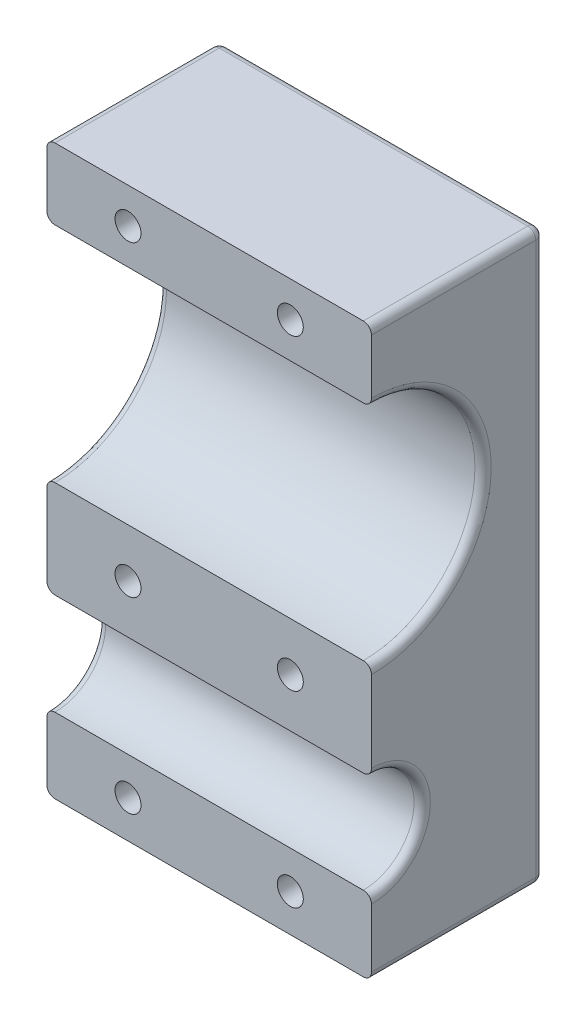
from build123d import *

# Parameters (mm, degrees)
SKETCH1_W           = 53.975
SKETCH1_H           = 88.9
SKETCH1_R           = 7.9375
SKETCH1_R_2         = 17.4625
BOSS_EXTRUDE1_DEPTH = 50.8
SKETCH5_R           = 2.032
CUT_EXTRUDE1_DEPTH  = 116.746060948
SKETCH5_3_R         = 3.5
CUT_EXTRUDE2_DEPTH  = 4.064
CUT_EXTRUDE3_DEPTH  = 2.54
FILLET1_R           = 1.27


with BuildPart() as part:
    # Sketch1 → Boss-Extrude1 (new body)
    with BuildSketch(Plane(origin=(0, 0, 0), x_dir=(0, 0, -1), z_dir=(1, 0, 0))):
        with Locations((26.9875, 44.45)):
            Rectangle(SKETCH1_W, SKETCH1_H)
        with Locations(Location((26.9875, 19.685, 0), (0, 0, 180))):
            Circle(SKETCH1_R, mode=Mode.SUBTRACT)
        with Locations(Location((26.9875, 60.325, 0), (0, 0, 180))):
            Circle(SKETCH1_R_2, mode=Mode.SUBTRACT)
    extrude(amount=BOSS_EXTRUDE1_DEPTH)

    # Sketch5 → Cut-Extrude1 (cut, through all)
    with BuildSketch(Plane.XY):
        with Locations((12.7, 83.34375)):
            Circle(SKETCH5_R)
        with Locations((12.7, 35.2425)):
            Circle(SKETCH5_R)
        with Locations((38.1, 83.34375)):
            Circle(SKETCH5_R)
        with Locations((38.1, 35.2425)):
            Circle(SKETCH5_R)
        with Locations((12.7, 5.87375)):
            Circle(SKETCH5_R)
        with Locations((38.1, 5.87375)):
            Circle(SKETCH5_R)
    extrude(amount=-CUT_EXTRUDE1_DEPTH, mode=Mode.SUBTRACT)

    # Sketch5_3 → Cut-Extrude2 (cut)
    with BuildSketch(Plane.XY):
        with Locations((38.1, 35.2425)):
            Circle(SKETCH5_3_R)
        with Locations((12.7, 83.34375)):
            Circle(SKETCH5_3_R)
        with Locations((38.1, 83.34375)):
            Circle(SKETCH5_3_R)
        with Locations((12.7, 35.2425)):
            Circle(SKETCH5_3_R)
        with Locations((38.1, 5.87375)):
            Circle(SKETCH5_3_R)
        with Locations((12.7, 5.87375)):
            Circle(SKETCH5_3_R)
    extrude(amount=-CUT_EXTRUDE2_DEPTH, mode=Mode.SUBTRACT)

    # Sketch6 → Cut-Extrude3 (cut)
    with BuildSketch(Plane(origin=(0, 0, -53.975), x_dir=(-1, 0, 0), z_dir=(0, 0, -1))):
        Polygon((-8.636, 83.34375), (-10.668, 86.863277241), (-14.732, 86.863277241), (-16.764, 83.34375), (-14.732, 79.824222759), (-10.668, 79.824222759), align=None)
        Polygon((-34.036, 83.34375), (-36.068, 86.863277241), (-40.132, 86.863277241), (-42.164, 83.34375), (-40.132, 79.824222759), (-36.068, 79.824222759), align=None)
        Polygon((-34.036, 35.2425), (-36.068, 38.762027241), (-40.132, 38.762027241), (-42.164, 35.2425), (-40.132, 31.722972759), (-36.068, 31.722972759), align=None)
        Polygon((-8.636, 35.2425), (-10.668, 38.762027241), (-14.732, 38.762027241), (-16.764, 35.2425), (-14.732, 31.722972759), (-10.668, 31.722972759), align=None)
        Polygon((-8.636, 5.87375), (-10.668, 9.393277241), (-14.732, 9.393277241), (-16.764, 5.87375), (-14.732, 2.354222759), (-10.668, 2.354222759), align=None)
        Polygon((-34.036, 5.87375), (-36.068, 9.393277241), (-40.132, 9.393277241), (-42.164, 5.87375), (-40.132, 2.354222759), (-36.068, 2.354222759), align=None)
    extrude(amount=-CUT_EXTRUDE3_DEPTH, mode=Mode.SUBTRACT)

    # Fillet1
    fillet1_edges = [part.edges().sort_by_distance(p)[0] for p in [
        (0, 60.325, -44.45),
        (50.8, 60.325, -44.45),
        (50.8, 88.9, -26.9875),
        (0, 19.685, -34.925),
        (50.8, 19.685, -34.925),
        (50.8, 44.45, 0),
        (50.8, 0, -26.9875),
        (0, 44.45, 0),
        (0, 88.9, -26.9875),
        (0, 44.45, -53.975),
        (0, 0, -26.9875),
        (25.4, 0, 0),
        (25.4, 88.9, 0),
        (25.4, 88.9, -53.975),
        (25.4, 0, -53.975),
        (50.8, 44.45, -53.975),
    ]]
    fillet(fillet1_edges, radius=FILLET1_R)

    # SurfaceCut1
    split(bisect_by=Plane.XY.offset(-26.9875), keep=Keep.BOTTOM)


solid = part.part
